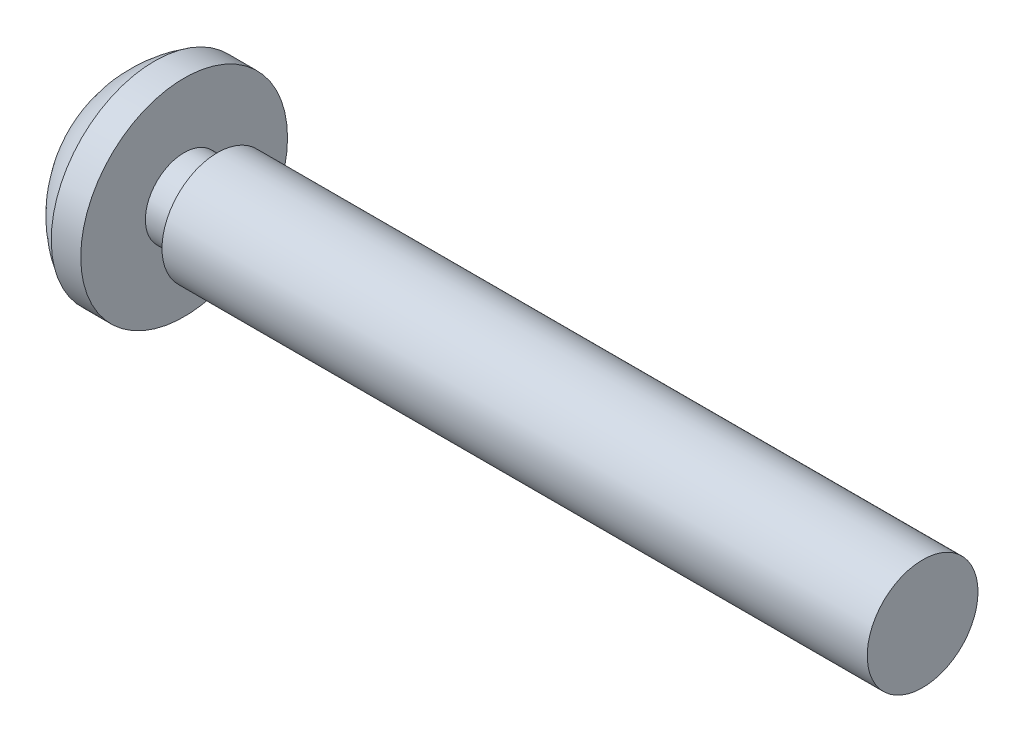
from build123d import *

# Parameters (mm, degrees)
CUT_EXTRUDE_5_DEPTH = 1.2


with BuildPart() as part:
    # 草图2 → 旋转1 (revolve)
    with BuildSketch(Plane.XY):
        with BuildLine():
            Line((0, 0), (0, 1.5))
            Line((0, 1.5), (-19.1, 1.5))
            Line((-19.1, 1.5), (-19.1, 1.05))
            Line((-19.1, 1.05), (-20, 1.05))
            Line((-20, 1.05), (-20, 2.8))
            Line((-20, 2.8), (-20.8, 2.8))
            ThreePointArc((-20.8, 2.8), (-21.971790212, 1.61245155), (-22.4, 0))
            Line((-22.4, 0), (0, 0))
        make_face()
    revolve(axis=Axis((0, 0, 0), (-1, 0, 0)))

    # 草图3 → 切除-拉伸5 (cut)
    with BuildSketch(Plane(origin=(-22.4, 0, 0), x_dir=(0, 0, -1), z_dir=(1, 0, 0))):
        with BuildLine():
            Line((0.375, 1.8), (-0.375, 1.8))
            Line((-0.375, 1.8), (-0.375, 0.675))
            ThreePointArc((-0.375, 0.675), (-0.462867966, 0.462867966), (-0.675, 0.375))
            Line((-0.675, 0.375), (-1.8, 0.375))
            Line((-1.8, 0.375), (-1.8, -0.375))
            Line((-1.8, -0.375), (-0.675, -0.375))
            ThreePointArc((-0.675, -0.375), (-0.462867966, -0.462867966), (-0.375, -0.675))
            Line((-0.375, -0.675), (-0.375, -1.8))
            Line((-0.375, -1.8), (0.375, -1.8))
            Line((0.375, -1.8), (0.375, -0.675))
            ThreePointArc((0.375, -0.675), (0.462867966, -0.462867966), (0.675, -0.375))
            Line((0.675, -0.375), (1.8, -0.375))
            Line((1.8, -0.375), (1.8, 0.375))
            Line((1.8, 0.375), (0.675, 0.375))
            ThreePointArc((0.675, 0.375), (0.462867966, 0.462867966), (0.375, 0.675))
            Line((0.375, 0.675), (0.375, 1.8))
        make_face()
    extrude(amount=CUT_EXTRUDE_5_DEPTH, mode=Mode.SUBTRACT)


solid = part.part
